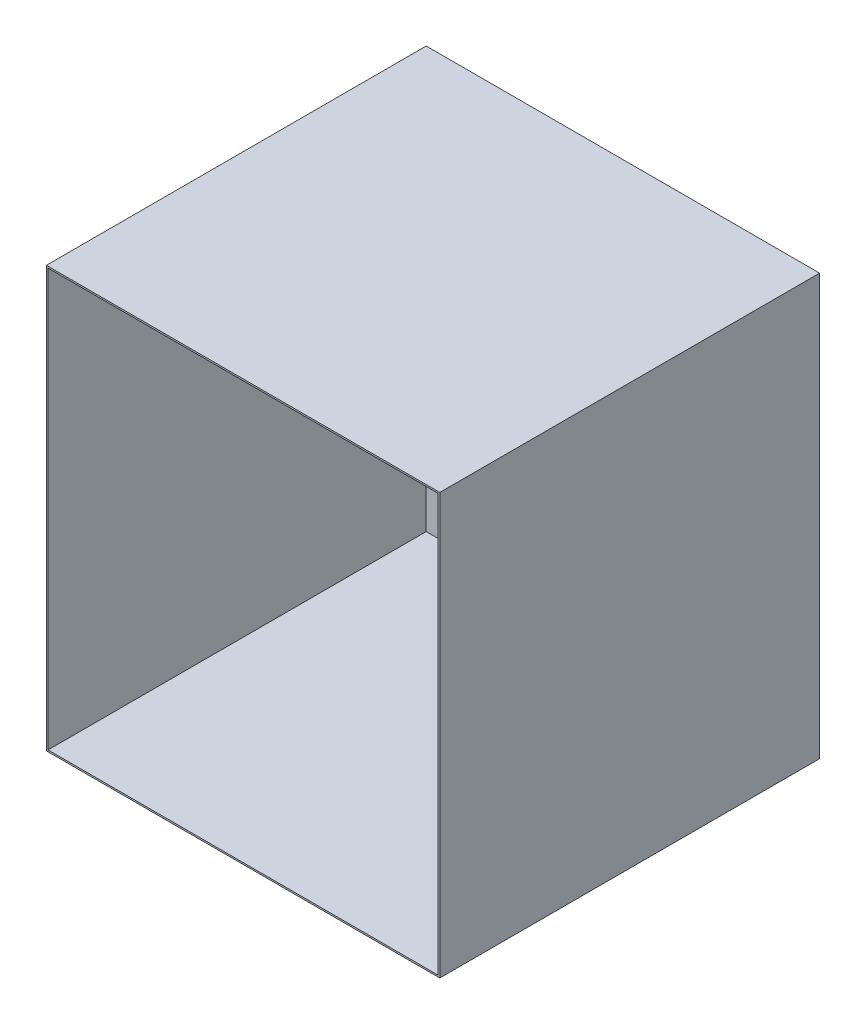
from build123d import *

# Parameters (mm, degrees)
ESQUISSE1_W        = 290
ESQUISSE1_H        = 310
ESQUISSE1_W_2      = 287.6
ESQUISSE1_H_2      = 307.6
BOSS_EXTRU_1_DEPTH = 280
ESQUISSE1_2_W      = 287.6
ESQUISSE1_2_H      = 307.6
BOSS_EXTRU_2_DEPTH = 1.2


with BuildPart() as part:
    # Esquisse1 → Boss.-Extru.1 (new body)
    with BuildSketch(Plane.XY):
        Rectangle(ESQUISSE1_W, ESQUISSE1_H)
        Rectangle(ESQUISSE1_W_2, ESQUISSE1_H_2, mode=Mode.SUBTRACT)
    extrude(amount=BOSS_EXTRU_1_DEPTH)

    # Esquisse1_2 → Boss.-Extru.2 (add)
    with BuildSketch(Plane.XY):
        Rectangle(ESQUISSE1_2_W, ESQUISSE1_2_H)
    extrude(amount=BOSS_EXTRU_2_DEPTH)


solid = part.part
